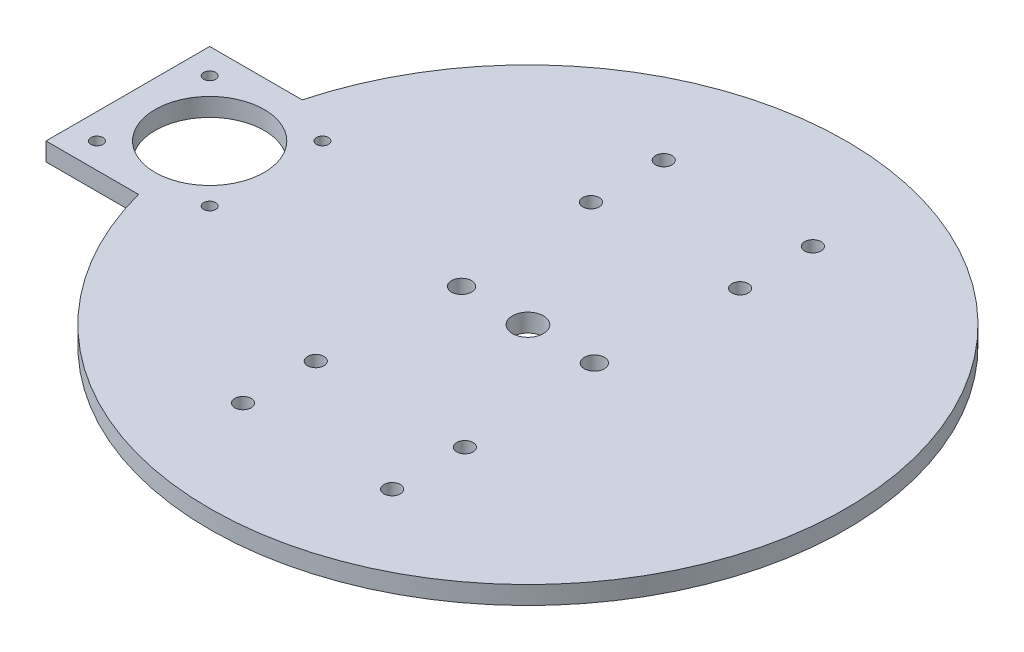
from build123d import *

# Parameters (mm, degrees)
SKETCH2_R           = 1.65
SKETCH2_R_2         = 2.25
SKETCH2_R_3         = 15
SKETCH2_R_4         = 2.75
SKETCH2_R_5         = 4.25
BOSS_EXTRUDE3_DEPTH = 5


with BuildPart() as part:
    # Sketch2 → Boss-Extrude3 (new body)
    with BuildSketch(Plane(origin=(0, 0, 0), x_dir=(1, 0, 0), z_dir=(0, 1, 0))):
        with BuildLine():
            Line((-84.557672626, 22.5), (-110, 22.5))
            Line((-110, 22.5), (-110, -22.5))
            Line((-110, -22.5), (-84.557672626, -22.5))
            ThreePointArc((-84.557672626, -22.5), (87.5, 0), (-84.557672626, 22.5))
        make_face()
        with Locations((-103, -15.5)):
            Circle(SKETCH2_R, mode=Mode.SUBTRACT)
        with Locations((-72, -15.5)):
            Circle(SKETCH2_R, mode=Mode.SUBTRACT)
        with Locations((-20.5, -57.830207885)):
            Circle(SKETCH2_R_2, mode=Mode.SUBTRACT)
        with Locations((-20.5, -37.830207885)):
            Circle(SKETCH2_R_2, mode=Mode.SUBTRACT)
        with Locations((20.5, -37.830207885)):
            Circle(SKETCH2_R_2, mode=Mode.SUBTRACT)
        with Locations((-87.5, 0)):
            Circle(SKETCH2_R_3, mode=Mode.SUBTRACT)
        with Locations((-103, 15.5)):
            Circle(SKETCH2_R, mode=Mode.SUBTRACT)
        with Locations((-72, 15.5)):
            Circle(SKETCH2_R, mode=Mode.SUBTRACT)
        with Locations((-18.25, 0)):
            Circle(SKETCH2_R_4, mode=Mode.SUBTRACT)
        Circle(SKETCH2_R_5, mode=Mode.SUBTRACT)
        with Locations((18.25, 0)):
            Circle(SKETCH2_R_4, mode=Mode.SUBTRACT)
        with Locations((-20.5, 37.830207885)):
            Circle(SKETCH2_R_2, mode=Mode.SUBTRACT)
        with Locations((-20.5, 57.830207885)):
            Circle(SKETCH2_R_2, mode=Mode.SUBTRACT)
        with Locations((20.5, 37.830207885)):
            Circle(SKETCH2_R_2, mode=Mode.SUBTRACT)
        with Locations((20.5, 57.830207885)):
            Circle(SKETCH2_R_2, mode=Mode.SUBTRACT)
        with Locations((20.5, -57.830207885)):
            Circle(SKETCH2_R_2, mode=Mode.SUBTRACT)
    extrude(amount=BOSS_EXTRUDE3_DEPTH)


solid = part.part
